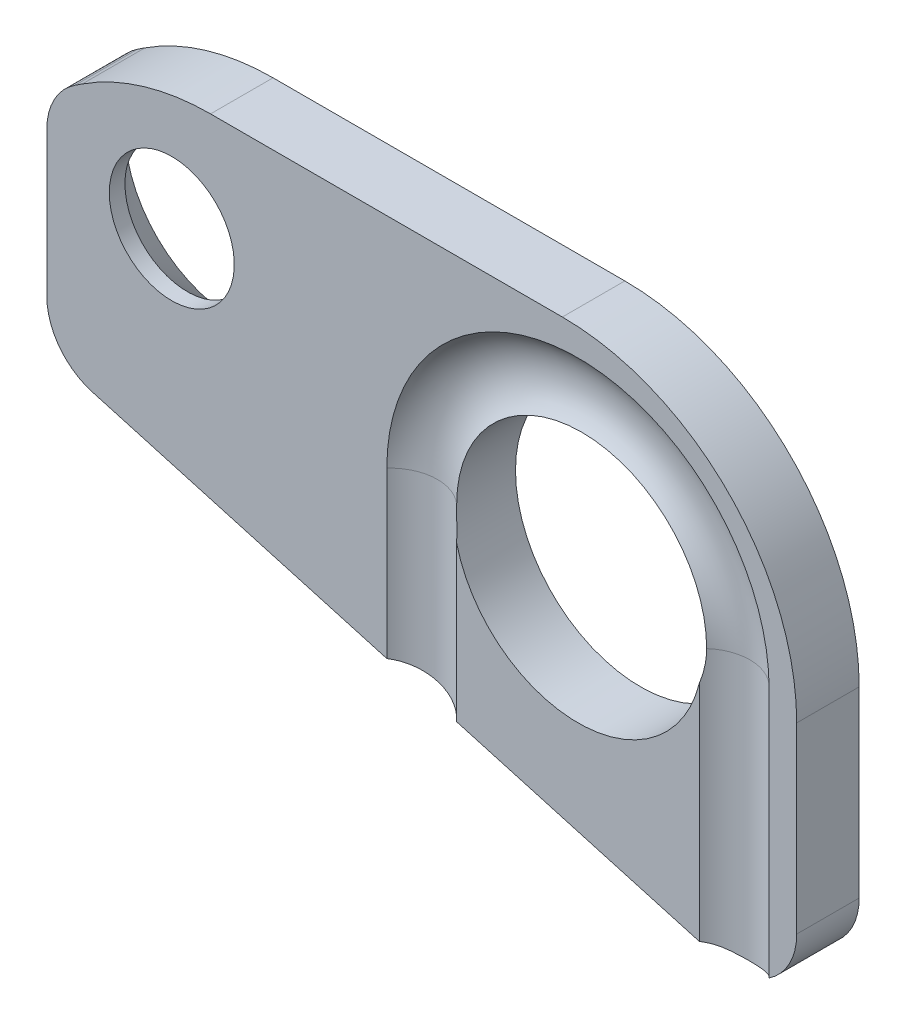
from build123d import *

# Parameters (mm, degrees)
SKETCH1_R            = 4
SKETCH1_R_2          = 2
BOSS_EXTRUDE1_DEPTH  = 2
CUT_SWEEP2_PROFILE_R = 1.5
CHAMFER1_SIZE        = 1.5


with BuildPart() as part:
    # Sketch1 → Boss-Extrude1 (new body)
    with BuildSketch(Plane.XY):
        with BuildLine():
            Line((-13, 8.952546351), (-13, 4.3251588))
            ThreePointArc((-13, 4.3251588), (-12.595694104, 3.119438963), (-11.546239674, 2.401198764))
            Line((-11.546239674, 2.401198764), (8.453760326, -3.277086269))
            ThreePointArc((8.453760326, -3.277086269), (10.205719837, -2.948820337), (11, -1.353126233))
            Line((11, -1.353126233), (11, 4.5))
            ThreePointArc((11, 4.5), (8.803300859, 9.803300859), (3.5, 12))
            Line((3.5, 12), (-7.759513818, 12))
            ThreePointArc((-7.759513818, 12), (-9.900828742, 11.687820977), (-11.86388404, 10.777272105))
            Line((-11.86388404, 10.777272105), (-12.094498726, 10.626485579))
            ThreePointArc((-12.094498726, 10.626485579), (-12.759118736, 9.904124658), (-13, 8.952546351))
        make_face()
        with Locations((4, 5)):
            Circle(SKETCH1_R, mode=Mode.SUBTRACT)
        with Locations((-9, 8.2)):
            Circle(SKETCH1_R_2, mode=Mode.SUBTRACT)
    extrude(amount=BOSS_EXTRUDE1_DEPTH)

    # Cut-Sweep2: sweep along a path in Sketch19
    with BuildLine(Plane.XY.offset(3)) as cut_sweep2_path:
        Line((-1, -3.013992868), (-1, 5))
        ThreePointArc((-1, 5), (4, 10), (9, 5))
        Line((9, 5), (9, -6.134852042))
    # Cut-Sweep2 profile (on start of the path) → Cut-Sweep2 (sweep, cut)
    with BuildSketch(Plane(origin=(-1, -3.013992868, 3), x_dir=(0, 0, 1), z_dir=(0, 1, 0))):
        Circle(CUT_SWEEP2_PROFILE_R)
    sweep(path=cut_sweep2_path.line, mode=Mode.SUBTRACT)

    # Chamfer1
    chamfer1_edges = [part.edges().sort_by_distance(p)[0] for p in [
        (-11, 8.2, 0),
    ]]
    chamfer(chamfer1_edges, length=CHAMFER1_SIZE)


solid = part.part
